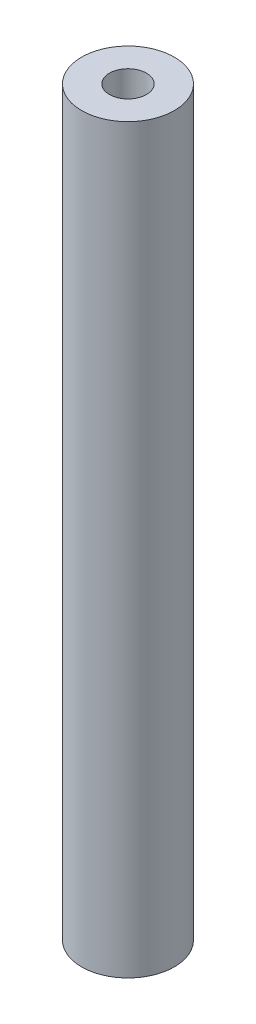
from build123d import *

# Parameters (mm, degrees)
SKETCH1_R           = 2.5
SKETCH1_R_2         = 1
BOSS_EXTRUDE1_DEPTH = 40


with BuildPart() as part:
    # Sketch1 → Boss-Extrude1 (new body)
    with BuildSketch(Plane(origin=(0, 0, 0), x_dir=(1, 0, 0), z_dir=(0, 1, 0))):
        Circle(SKETCH1_R)
        Circle(SKETCH1_R_2, mode=Mode.SUBTRACT)
    extrude(amount=BOSS_EXTRUDE1_DEPTH)


solid = part.part
